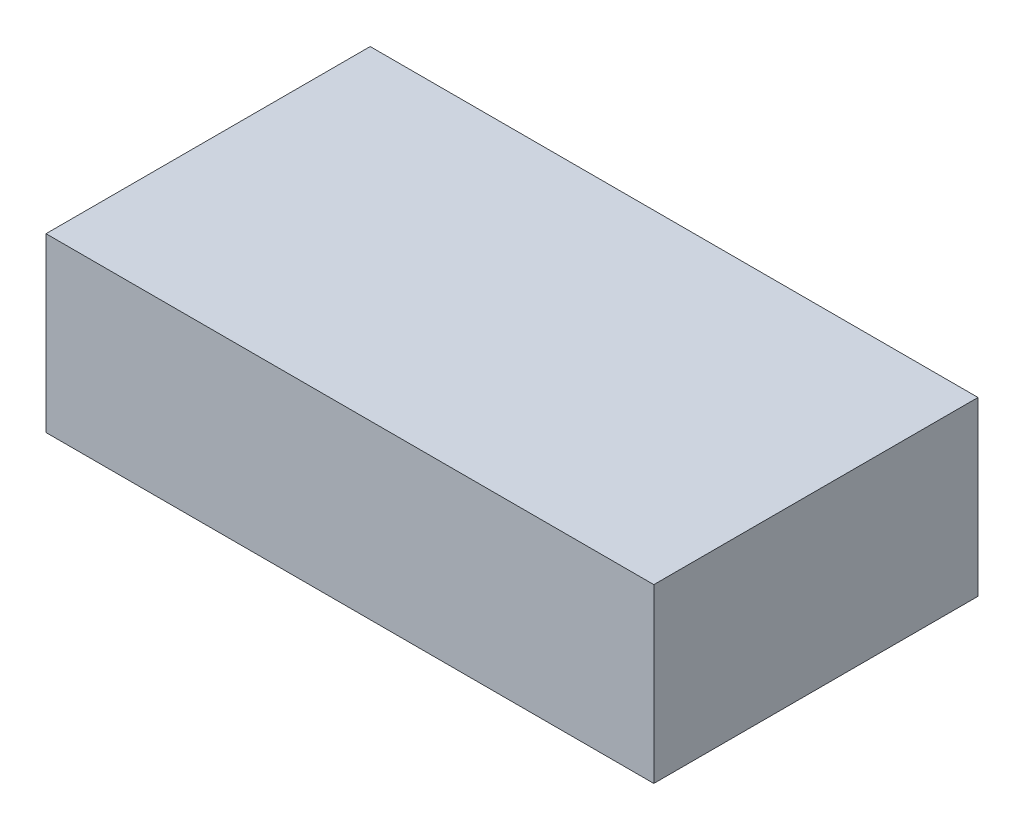
from build123d import *

# Parameters (mm, degrees)
SKETCH1_W           = 152.4
SKETCH1_H           = 81.28
BOSS_EXTRUDE1_DEPTH = 21.59


with BuildPart() as part:
    # Sketch1 → Boss-Extrude1 (new body, symmetric)
    with BuildSketch(Plane(origin=(0, 0, 0), x_dir=(1, 0, 0), z_dir=(0, 1, 0))):
        Rectangle(SKETCH1_W, SKETCH1_H)
    extrude(amount=BOSS_EXTRUDE1_DEPTH, both=True)


solid = part.part
